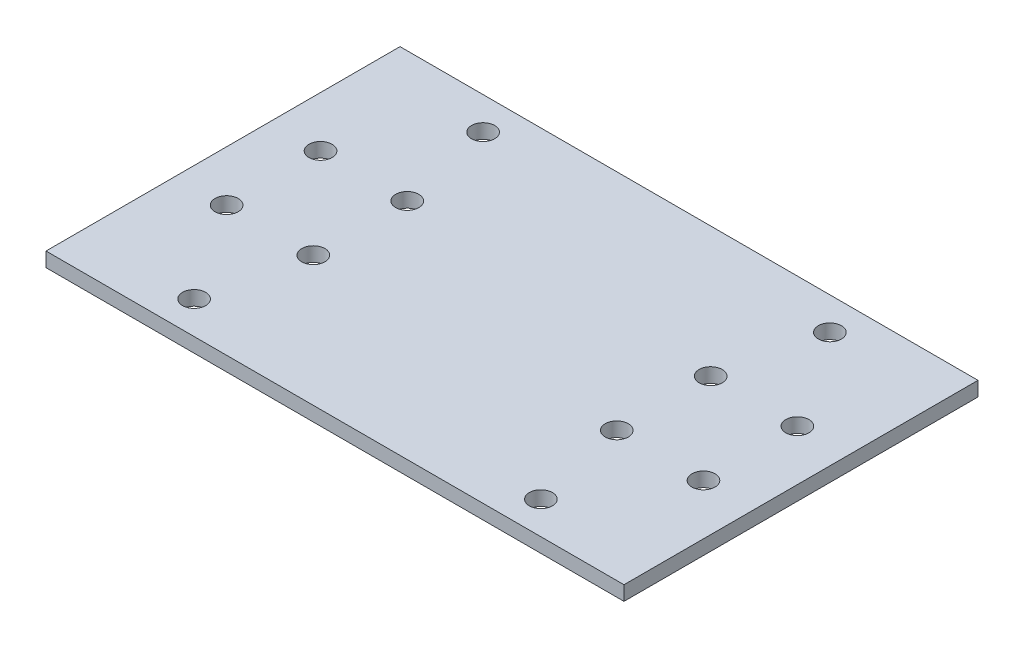
from build123d import *

# Parameters (mm, degrees)
SKETCH_1_W      = 80
SKETCH_1_H      = 49
SKETCH_1_R      = 1.6
EXTRUDE_1_DEPTH = 2


with BuildPart() as part:
    # 草圖1 → 填料-伸長1 (new body)
    with BuildSketch(Plane(origin=(0, 0, 0), x_dir=(1, 0, 0), z_dir=(0, 1, 0))):
        Rectangle(SKETCH_1_W, SKETCH_1_H)
        with Locations((-33, 6.5)):
            Circle(SKETCH_1_R, mode=Mode.SUBTRACT)
        with Locations((33, 6.5)):
            Circle(SKETCH_1_R, mode=Mode.SUBTRACT)
        with Locations((33, -6.5)):
            Circle(SKETCH_1_R, mode=Mode.SUBTRACT)
        with Locations((-33, -6.5)):
            Circle(SKETCH_1_R, mode=Mode.SUBTRACT)
        with Locations((-21, 6.5)):
            Circle(SKETCH_1_R, mode=Mode.SUBTRACT)
        with Locations((21, 6.5)):
            Circle(SKETCH_1_R, mode=Mode.SUBTRACT)
        with Locations((-21, -6.5)):
            Circle(SKETCH_1_R, mode=Mode.SUBTRACT)
        with Locations((21, -6.5)):
            Circle(SKETCH_1_R, mode=Mode.SUBTRACT)
        with Locations((-24, -20)):
            Circle(SKETCH_1_R, mode=Mode.SUBTRACT)
        with Locations((24, -20)):
            Circle(SKETCH_1_R, mode=Mode.SUBTRACT)
        with Locations((24, 20)):
            Circle(SKETCH_1_R, mode=Mode.SUBTRACT)
        with Locations((-24, 20)):
            Circle(SKETCH_1_R, mode=Mode.SUBTRACT)
    extrude(amount=EXTRUDE_1_DEPTH)


solid = part.part
